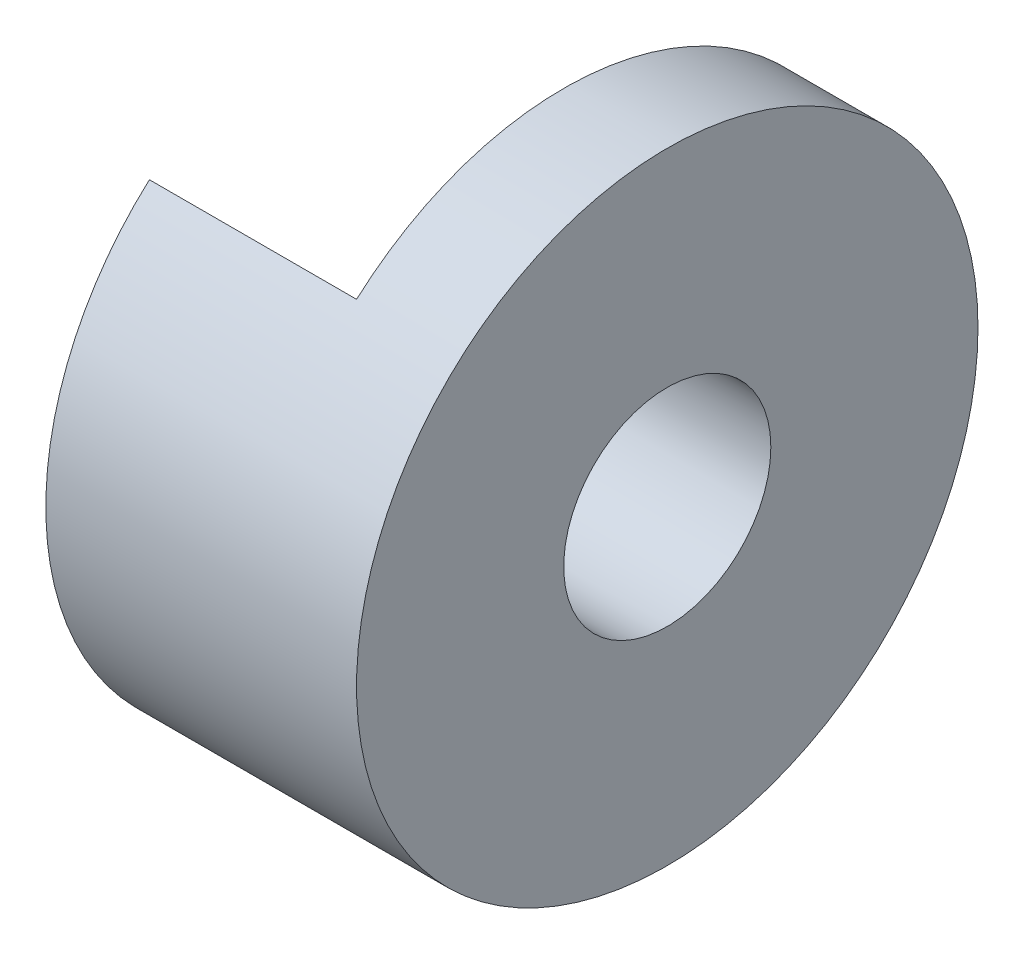
from build123d import *

# Parameters (mm, degrees)
SKETCH1_R           = 3
SKETCH1_R_2         = 1
BOSS_EXTRUDE1_DEPTH = 1.5
CUT_EXTRUDE1_DEPTH  = 2


with BuildPart() as part:
    # Sketch1 → Boss-Extrude1 (new body, symmetric)
    with BuildSketch(Plane(origin=(0, 0, 0), x_dir=(0, 0, -1), z_dir=(1, 0, 0))):
        Circle(SKETCH1_R)
        Circle(SKETCH1_R_2, mode=Mode.SUBTRACT)
    extrude(amount=BOSS_EXTRUDE1_DEPTH, both=True)

    # Sketch2 → Cut-Extrude1 (cut)
    with BuildSketch(Plane.ZY.offset(1.5)):
        with BuildLine():
            Line((2, -2.236067977), (2, 2.236067977))
            ThreePointArc((2, 2.236067977), (-1.224744871, 2.738612788), (-3, 0))
            Line((-3, 0), (-1, 0))
            ThreePointArc((-1, 0), (0, 1), (1, 0))
            ThreePointArc((1, 0), (0.707106781, -0.707106781), (0, -1))
            Line((0, -1), (0, -3))
            ThreePointArc((0, -3), (1.070466269, -2.802517077), (2, -2.236067977))
        make_face()
    extrude(amount=-CUT_EXTRUDE1_DEPTH, mode=Mode.SUBTRACT)


solid = part.part
